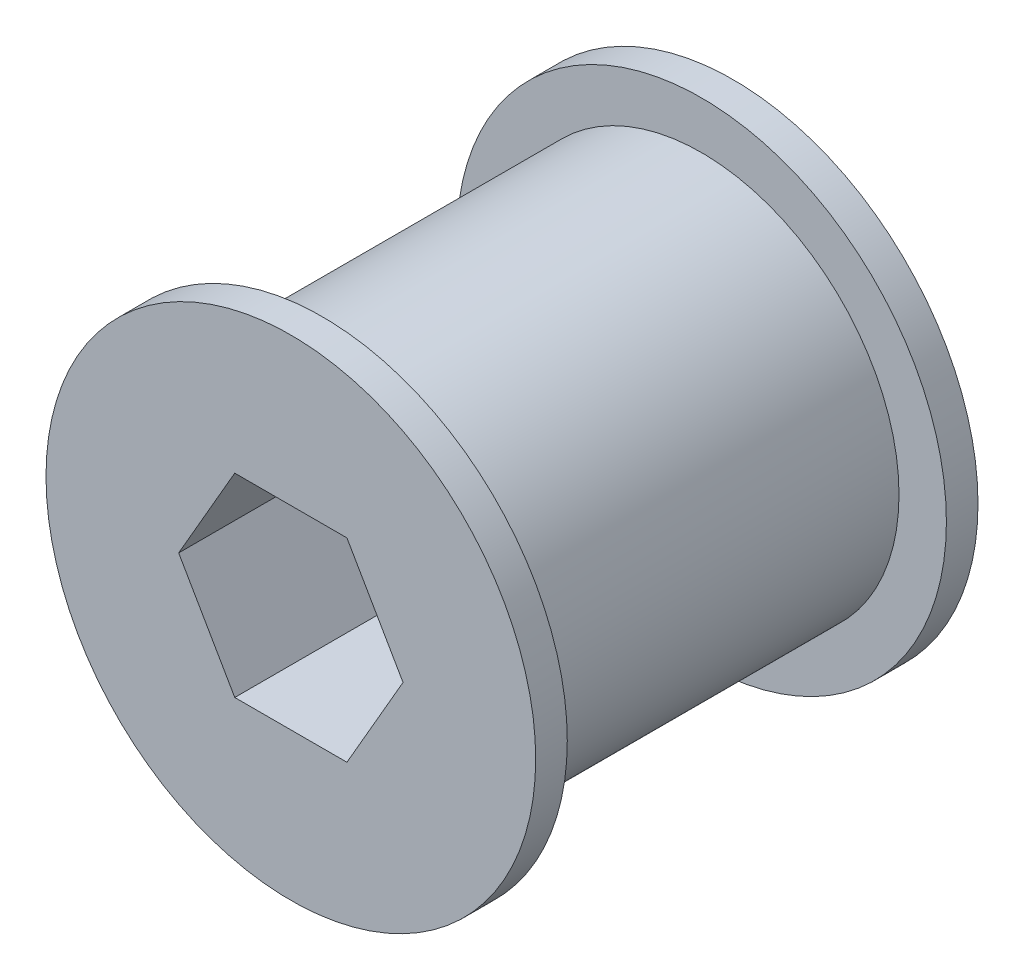
from build123d import *

# Parameters (mm, degrees)
SKETCH1_R           = 12.5
BOSS_EXTRUDE1_DEPTH = 12
SKETCH2_R           = 15.5
BOSS_EXTRUDE2_DEPTH = 2
CUT_EXTRUDE1_DEPTH  = 14
SKETCH5_R           = 2.2
CUT_EXTRUDE2_DEPTH  = 14
SKETCH6_R           = 6.15
CUT_EXTRUDE3_DEPTH  = 10


with BuildPart() as part:
    # Sketch1 → Boss-Extrude1 (new body)
    with BuildSketch(Plane.XY):
        Circle(SKETCH1_R)
    boss_extrude1 = extrude(amount=BOSS_EXTRUDE1_DEPTH)

    # Sketch2 → Boss-Extrude2 (add)
    with BuildSketch(Plane(origin=(0, 0, 12), x_dir=(-1, 0, 0), z_dir=(0, 0, -1))):
        Circle(SKETCH2_R)
    boss_extrude2 = extrude(amount=-BOSS_EXTRUDE2_DEPTH)

    # Sketch3 → Cut-Extrude1 (cut)
    with BuildSketch(Plane.XY):
        Polygon((3.550704156, -6.15), (7.101408311, 0), (3.550704156, 6.15), (-3.550704156, 6.15), (-7.101408311, 0), (-3.550704156, -6.15), align=None)
    extrude(amount=CUT_EXTRUDE1_DEPTH, mode=Mode.SUBTRACT)

    # Mirror1: Boss-Extrude1, Boss-Extrude2 across plane
    add(boss_extrude1.mirror(Plane.XY))
    add(boss_extrude2.mirror(Plane.XY))

    # Sketch5 → Cut-Extrude2 (cut)
    with BuildSketch(Plane.XY):
        Circle(SKETCH5_R)
    extrude(amount=-CUT_EXTRUDE2_DEPTH, mode=Mode.SUBTRACT)

    # Sketch6 → Cut-Extrude3 (cut)
    with BuildSketch(Plane(origin=(0, 0, -14), x_dir=(-1, 0, 0), z_dir=(0, 0, -1))):
        Circle(SKETCH6_R)
    extrude(amount=-CUT_EXTRUDE3_DEPTH, mode=Mode.SUBTRACT)


solid = part.part
